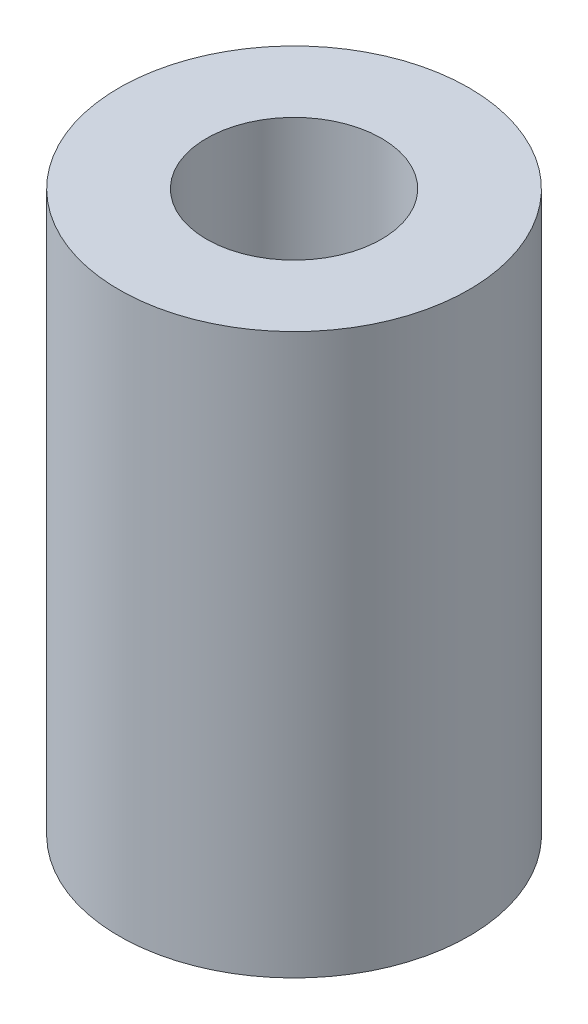
from build123d import *

# Parameters (mm, degrees)
SKETCH1_W = 2.5
SKETCH1_H = 16


with BuildPart() as part:
    # Sketch1 → Revolve1 (revolve)
    with BuildSketch(Plane.XY):
        with Locations((3.75, 8)):
            Rectangle(SKETCH1_W, SKETCH1_H)
    revolve(axis=Axis((0, 0, 0), (0, 1, 0)))


solid = part.part
